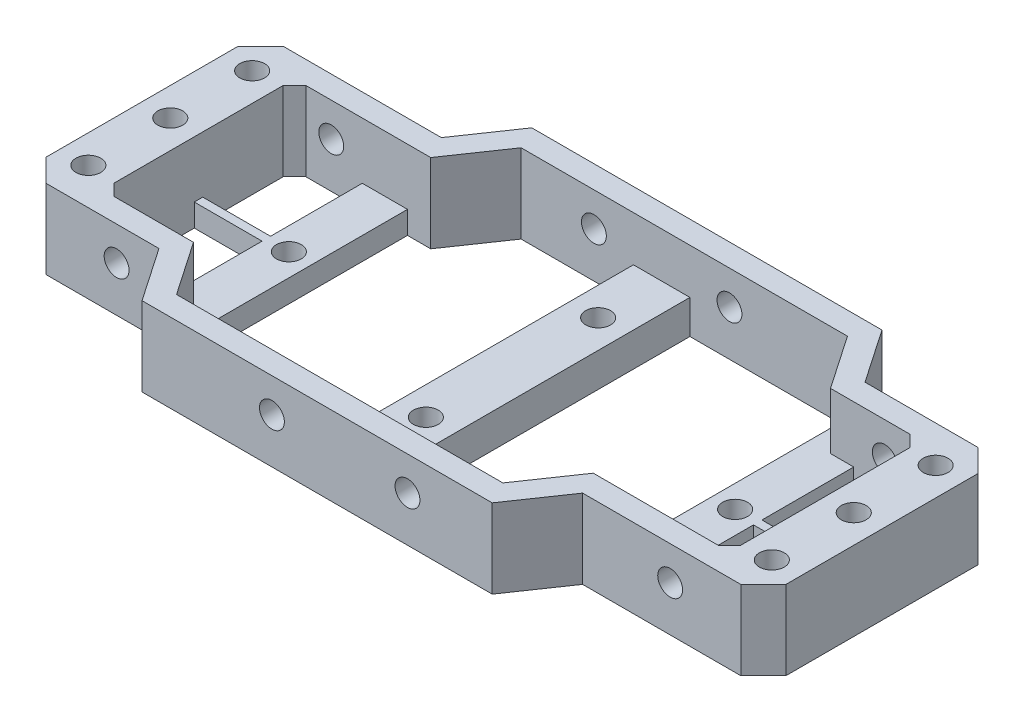
from build123d import *

# Parameters (mm, degrees)
BOSS_EXTRUDE1_DEPTH = 14
CUT_EXTRUDE1_REACH  = 16
SKETCH2_R           = 2.2
SKETCH5_R           = 2.2
CUT_EXTRUDE2_DEPTH  = 62
BOSS_EXTRUDE2_REACH = 59
SKETCH6_W           = 10
SKETCH6_H           = 6
SKETCH7_W           = 12
SKETCH7_H           = 1.5
SKETCH7_R           = 2.2
BOSS_EXTRUDE3_DEPTH = 4
CUT_EXTRUDE3_REACH  = 16
SKETCH8_R           = 2.2
CHAMFER1_SIZE       = 4
CHAMFER2_SIZE       = 2


with BuildPart() as part:
    # Sketch1 → Boss-Extrude1 (new body)
    with BuildSketch(Plane(origin=(0, 0, 0), x_dir=(1, 0, 0), z_dir=(0, 1, 0))):
        Polygon((-104.176003517, -21), (-104.176003517, 21), (-72.176003517, 21), (-65.676003517, 30.5), (-3.676003517, 30.5), (2.823996483, 21), (26.823996483, 21), (26.823996483, -21), (-5.176003517, -21), (-11.676003517, -30.5), (-73.676003517, -30.5), (-80.176003517, -21), align=None)
        Polygon((-94.176003517, -17), (-94.176003517, 17), (-70.066165861, 17), (-63.566165861, 26.5), (-5.785841173, 26.5), (0.714158827, 17), (16.823996483, 17), (16.823996483, -17), (-7.285841173, -17), (-13.785841173, -26.5), (-71.566165861, -26.5), (-78.066165861, -17), align=None, mode=Mode.SUBTRACT)
    extrude(amount=BOSS_EXTRUDE1_DEPTH)

    # Sketch2 → Cut-Extrude1 (cut, up to next)
    with BuildSketch(Plane(origin=(0, 0, 0), x_dir=(-1, 0, 0), z_dir=(0, -1, 0)), mode=Mode.PRIVATE) as cut_extrude1_sk1:
        with Locations(Location((99.176003517, 14.5, 0), (0, 0, 90))):  # turned: the seam where the file's is
            Circle(SKETCH2_R)
    cut_extrude1_tool1 = extrude(cut_extrude1_sk1.sketch, amount=-CUT_EXTRUDE1_REACH, mode=Mode.PRIVATE) & part.part
    add(cut_extrude1_tool1.solids().sort_by_distance((-99.176004, 0, -14.5))[0], mode=Mode.SUBTRACT)
    # Sketch2 → Cut-Extrude1 (cut, up to next)
    with BuildSketch(Plane(origin=(0, 0, 0), x_dir=(-1, 0, 0), z_dir=(0, -1, 0)), mode=Mode.PRIVATE) as cut_extrude1_sk2:
        with Locations(Location((99.176003517, 0, 0), (0, 0, 90))):  # turned: the seam where the file's is
            Circle(SKETCH2_R)
    cut_extrude1_tool2 = extrude(cut_extrude1_sk2.sketch, amount=-CUT_EXTRUDE1_REACH, mode=Mode.PRIVATE) & part.part
    add(cut_extrude1_tool2.solids().sort_by_distance((-99.176004, 0, 0))[0], mode=Mode.SUBTRACT)
    # Sketch2 → Cut-Extrude1 (cut, up to next)
    with BuildSketch(Plane(origin=(0, 0, 0), x_dir=(-1, 0, 0), z_dir=(0, -1, 0)), mode=Mode.PRIVATE) as cut_extrude1_sk3:
        with Locations(Location((99.176003517, -14.5, 0), (0, 0, 90))):  # turned: the seam where the file's is
            Circle(SKETCH2_R)
    cut_extrude1_tool3 = extrude(cut_extrude1_sk3.sketch, amount=-CUT_EXTRUDE1_REACH, mode=Mode.PRIVATE) & part.part
    add(cut_extrude1_tool3.solids().sort_by_distance((-99.176004, 0, 14.5))[0], mode=Mode.SUBTRACT)
    # Sketch2 → Cut-Extrude1 (cut, up to next)
    with BuildSketch(Plane(origin=(0, 0, 0), x_dir=(-1, 0, 0), z_dir=(0, -1, 0)), mode=Mode.PRIVATE) as cut_extrude1_sk4:
        with Locations(Location((-21.823996483, -14.5, 0), (0, 0, 90))):  # turned: the seam where the file's is
            Circle(SKETCH2_R)
    cut_extrude1_tool4 = extrude(cut_extrude1_sk4.sketch, amount=-CUT_EXTRUDE1_REACH, mode=Mode.PRIVATE) & part.part
    add(cut_extrude1_tool4.solids().sort_by_distance((21.823996, 0, 14.5))[0], mode=Mode.SUBTRACT)
    # Sketch2 → Cut-Extrude1 (cut, up to next)
    with BuildSketch(Plane(origin=(0, 0, 0), x_dir=(-1, 0, 0), z_dir=(0, -1, 0)), mode=Mode.PRIVATE) as cut_extrude1_sk5:
        with Locations(Location((-21.823996483, 0, 0), (0, 0, 90))):  # turned: the seam where the file's is
            Circle(SKETCH2_R)
    cut_extrude1_tool5 = extrude(cut_extrude1_sk5.sketch, amount=-CUT_EXTRUDE1_REACH, mode=Mode.PRIVATE) & part.part
    add(cut_extrude1_tool5.solids().sort_by_distance((21.823996, 0, 0))[0], mode=Mode.SUBTRACT)
    # Sketch2 → Cut-Extrude1 (cut, up to next)
    with BuildSketch(Plane(origin=(0, 0, 0), x_dir=(-1, 0, 0), z_dir=(0, -1, 0)), mode=Mode.PRIVATE) as cut_extrude1_sk6:
        with Locations(Location((-21.823996483, 14.5, 0), (0, 0, 90))):  # turned: the seam where the file's is
            Circle(SKETCH2_R)
    cut_extrude1_tool6 = extrude(cut_extrude1_sk6.sketch, amount=-CUT_EXTRUDE1_REACH, mode=Mode.PRIVATE) & part.part
    add(cut_extrude1_tool6.solids().sort_by_distance((21.823996, 0, -14.5))[0], mode=Mode.SUBTRACT)

    # Sketch5 → Cut-Extrude2 (cut, through all)
    with BuildSketch(Plane(origin=(0, 0, -30.5), x_dir=(-1, 0, 0), z_dir=(0, 0, -1))):
        with Locations((50.676003517, 8)):
            Circle(SKETCH5_R)
        with Locations((26.676003517, 8)):
            Circle(SKETCH5_R)
        with Locations(Location((87.676003517, 8, 0), (0, 0, 180))):  # turned: the seam where the file's is
            Circle(SKETCH5_R)
        with Locations(Location((-10.323996483, 8, 0), (0, 0, 180))):  # turned: the seam where the file's is
            Circle(SKETCH5_R)
    extrude(amount=-CUT_EXTRUDE2_DEPTH, mode=Mode.SUBTRACT)

    # Sketch6 → Boss-Extrude2 (add, up to next)
    with BuildSketch(Plane(origin=(0, 0, 26.5), x_dir=(-1, 0, 0), z_dir=(0, 0, -1)), mode=Mode.PRIVATE) as boss_extrude2_sk1:
        with Locations((38.676003517, 3)):
            Rectangle(SKETCH6_W, SKETCH6_H)
    boss_extrude2_tool1 = extrude(boss_extrude2_sk1.sketch, amount=BOSS_EXTRUDE2_REACH, mode=Mode.PRIVATE) - part.part
    add(boss_extrude2_tool1.solids().sort_by_distance((-38.676004, 3, 26.5))[0])

    # Sketch7 → Boss-Extrude3 (add)
    with BuildSketch(Plane.XZ):
        with Locations((-88.176003517, 0)):
            Rectangle(SKETCH7_W, SKETCH7_H)
        Polygon((-78.066165861, 17), (-82.176003517, 17), (-82.176003517, 0.75), (-82.176003517, -0.75), (-82.176003517, -17), (-74.176003517, -17), (-74.176003517, 22.685621887), align=None)
        with Locations(Location((-78.176003517, 0, 0), (0, 0, 270))):  # turned: the seam where the file's is
            Circle(SKETCH7_R, mode=Mode.SUBTRACT)
        Polygon((4.823996483, 0.75), (4.823996483, 17), (-3.176003517, 17), (-3.176003517, -22.685621887), (0.714158827, -17), (4.823996483, -17), (4.823996483, -0.75), align=None)
        with Locations(Location((0.823996483, 0, 0), (0, 0, 270))):  # turned: the seam where the file's is
            Circle(SKETCH7_R, mode=Mode.SUBTRACT)
        with Locations((10.823996483, 0)):
            Rectangle(SKETCH7_W, SKETCH7_H)
    extrude(amount=-BOSS_EXTRUDE3_DEPTH)

    # Sketch8 → Cut-Extrude3 (cut, up to next)
    with BuildSketch(Plane(origin=(0, 0, 0), x_dir=(-1, 0, 0), z_dir=(0, -1, 0)), mode=Mode.PRIVATE) as cut_extrude3_sk1:
        with Locations(Location((38.676003517, -15.25, 0), (0, 0, 90))):  # turned: the seam where the file's is
            Circle(SKETCH8_R)
    cut_extrude3_tool1 = extrude(cut_extrude3_sk1.sketch, amount=-CUT_EXTRUDE3_REACH, mode=Mode.PRIVATE) & part.part
    add(cut_extrude3_tool1.solids().sort_by_distance((-38.676004, 0, 15.25))[0], mode=Mode.SUBTRACT)
    # Sketch8 → Cut-Extrude3 (cut, up to next)
    with BuildSketch(Plane(origin=(0, 0, 0), x_dir=(-1, 0, 0), z_dir=(0, -1, 0)), mode=Mode.PRIVATE) as cut_extrude3_sk2:
        with Locations(Location((38.676003517, 15.25, 0), (0, 0, 90))):  # turned: the seam where the file's is
            Circle(SKETCH8_R)
    cut_extrude3_tool2 = extrude(cut_extrude3_sk2.sketch, amount=-CUT_EXTRUDE3_REACH, mode=Mode.PRIVATE) & part.part
    add(cut_extrude3_tool2.solids().sort_by_distance((-38.676004, 0, -15.25))[0], mode=Mode.SUBTRACT)

    # Chamfer1
    chamfer1_edges = [part.edges().sort_by_distance(p)[0] for p in [
        (-104.176003517, 7, 21),
        (-104.176003517, 7, -21),
        (26.823996483, 7, -21),
        (26.823996483, 7, 21),
    ]]
    chamfer(chamfer1_edges, length=CHAMFER1_SIZE)

    # Chamfer2
    chamfer2_edges = [part.edges().sort_by_distance(p)[0] for p in [
        (-94.176003517, 7, 17),
        (16.823996483, 7, 17),
        (16.823996483, 7, -17),
        (-94.176003517, 7, -17),
    ]]
    chamfer(chamfer2_edges, length=CHAMFER2_SIZE)


solid = part.part
